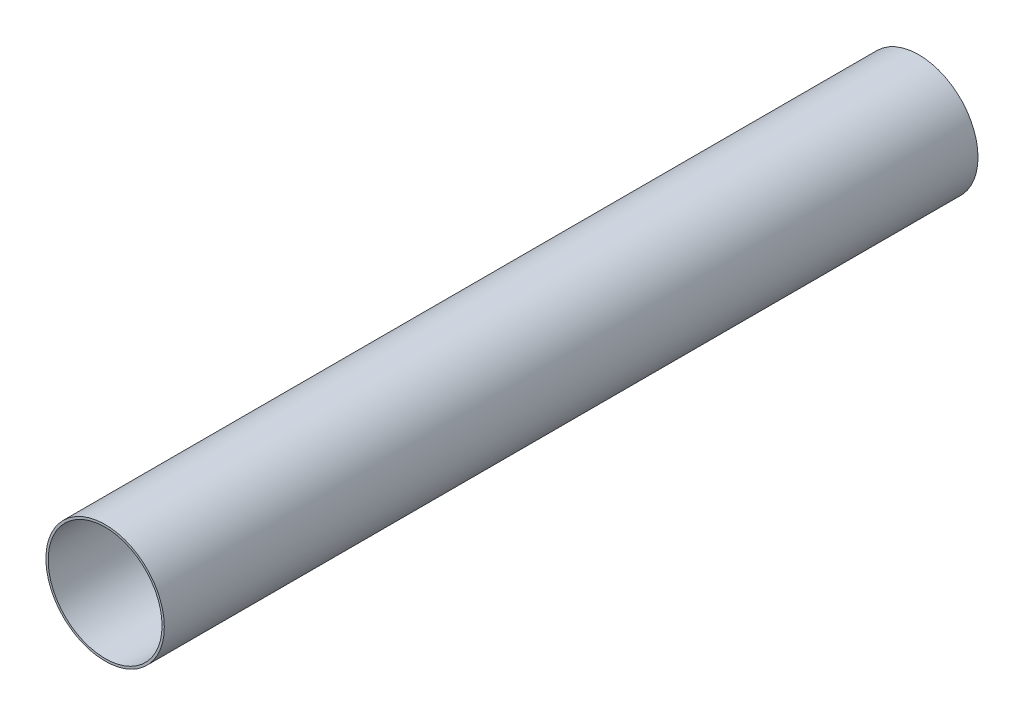
from build123d import *

# Parameters (mm, degrees)
SKETCH1_R           = 39.624
SKETCH1_R_2         = 38.1
BOSS_EXTRUDE1_DEPTH = 544.5125


with BuildPart() as part:
    # Sketch1 → Boss-Extrude1 (new body)
    with BuildSketch(Plane.XY):
        Circle(SKETCH1_R)
        Circle(SKETCH1_R_2, mode=Mode.SUBTRACT)
    extrude(amount=BOSS_EXTRUDE1_DEPTH)


solid = part.part
